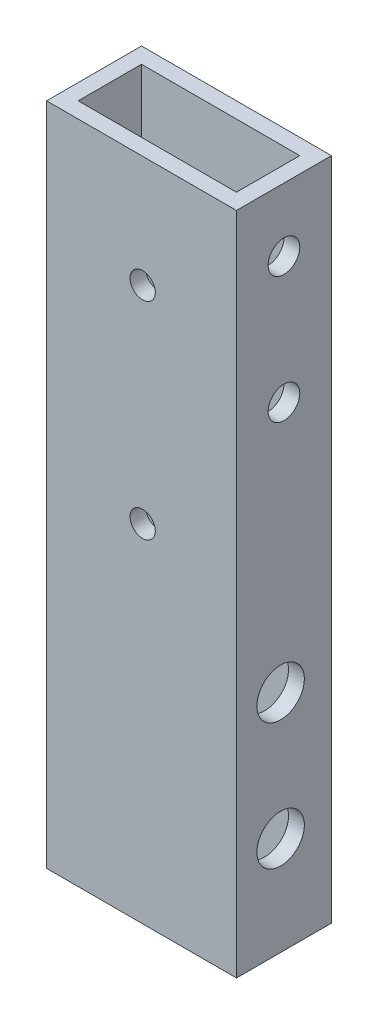
from build123d import *

# Parameters (mm, degrees)
SKETCH1_W           = 38.1
SKETCH1_H           = 19.05
SKETCH1_W_2         = 31.75
SKETCH1_H_2         = 12.7
BOSS_EXTRUDE1_DEPTH = 133.35
SKETCH2_R           = 3.175
CUT_EXTRUDE1_DEPTH  = 39.1
SKETCH3_R           = 2.0193
CUT_EXTRUDE2_DEPTH  = 39.1
CUT_EXTRUDE3_REACH  = 5.175
SKETCH4_R           = 4.7625
SKETCH5_R           = 2.54
CUT_EXTRUDE4_DEPTH  = 20.05


with BuildPart() as part:
    # Sketch1 → Boss-Extrude1 (new body)
    with BuildSketch(Plane(origin=(0, 0, 0), x_dir=(1, 0, 0), z_dir=(0, 1, 0))):
        with Locations((19.05, 9.525)):
            Rectangle(SKETCH1_W, SKETCH1_H)
        with Locations((19.05, 9.525)):
            Rectangle(SKETCH1_W_2, SKETCH1_H_2, mode=Mode.SUBTRACT)
    extrude(amount=BOSS_EXTRUDE1_DEPTH)

    # Sketch2 → Cut-Extrude1 (cut, through all)
    with BuildSketch(Plane(origin=(38.1, 0, 0), x_dir=(0, 0, -1), z_dir=(1, 0, 0))):
        with Locations((9.525, 95.25)):
            Circle(SKETCH2_R)
        with Locations((9.525, 120.65)):
            Circle(SKETCH2_R)
    extrude(amount=-CUT_EXTRUDE1_DEPTH, mode=Mode.SUBTRACT)

    # Sketch3 → Cut-Extrude2 (cut, through all)
    with BuildSketch(Plane.ZY):
        with Locations((-8.8564, 19.789753907)):
            Circle(SKETCH3_R)
        with Locations((-8.8564, 45.189753907)):
            Circle(SKETCH3_R)
    extrude(amount=-CUT_EXTRUDE2_DEPTH, mode=Mode.SUBTRACT)

    # Sketch4 → Cut-Extrude3 (cut, up to next)
    with BuildSketch(Plane.ZY.offset(-34.925), mode=Mode.PRIVATE) as cut_extrude3_sk1:
        with Locations((-8.8564, 45.189753907)):
            Circle(SKETCH4_R)
    cut_extrude3_tool1 = extrude(cut_extrude3_sk1.sketch, amount=-CUT_EXTRUDE3_REACH, mode=Mode.PRIVATE) & part.part
    add(cut_extrude3_tool1.solids().sort_by_distance((34.925, 45.189754, -8.8564))[0], mode=Mode.SUBTRACT)
    # Sketch4 → Cut-Extrude3 (cut, up to next)
    with BuildSketch(Plane.ZY.offset(-34.925), mode=Mode.PRIVATE) as cut_extrude3_sk2:
        with Locations((-8.8564, 19.789753907)):
            Circle(SKETCH4_R)
    cut_extrude3_tool2 = extrude(cut_extrude3_sk2.sketch, amount=-CUT_EXTRUDE3_REACH, mode=Mode.PRIVATE) & part.part
    add(cut_extrude3_tool2.solids().sort_by_distance((34.925, 19.789754, -8.8564))[0], mode=Mode.SUBTRACT)

    # Sketch5 → Cut-Extrude4 (cut, through all)
    with BuildSketch(Plane(origin=(0, 0, -19.05), x_dir=(-1, 0, 0), z_dir=(0, 0, -1))):
        with Locations((-19.272235529, 69.491227214)):
            Circle(SKETCH5_R)
        with Locations((-19.272235529, 110.945613607)):
            Circle(SKETCH5_R)
    extrude(amount=-CUT_EXTRUDE4_DEPTH, mode=Mode.SUBTRACT)


solid = part.part
